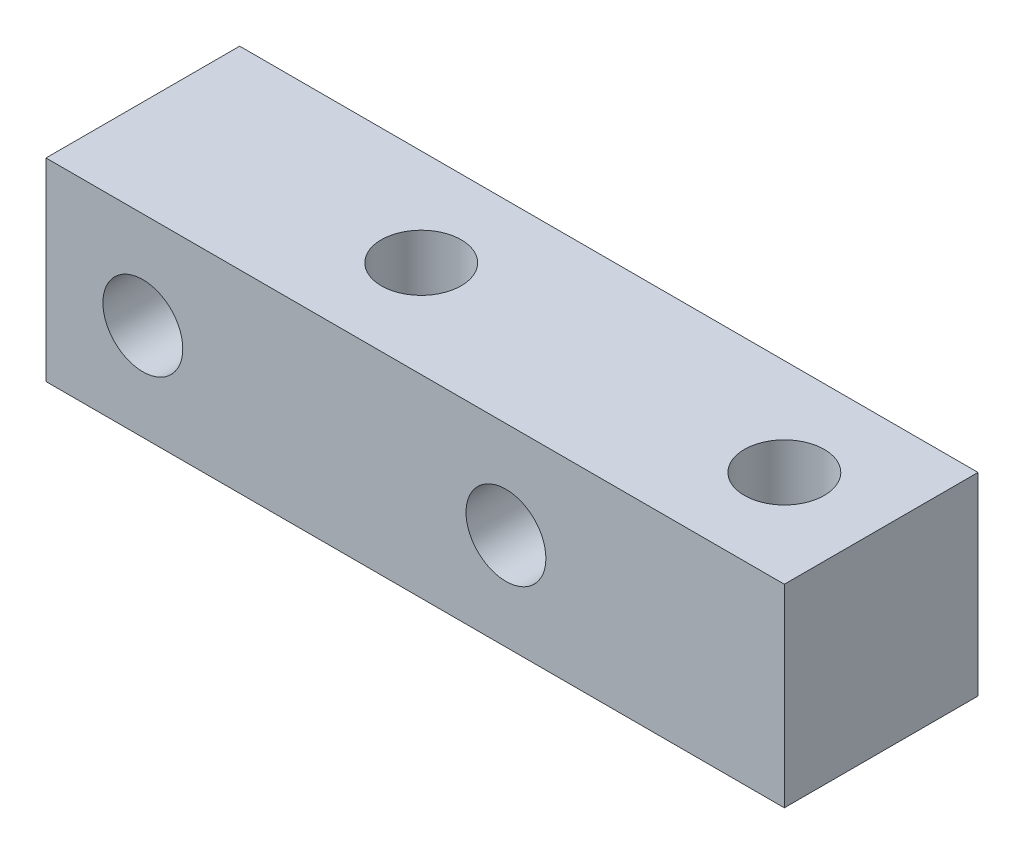
from build123d import *

# Parameters (mm, degrees)
SKETCH_1_W         = 30.5
SKETCH_1_H         = 8
EXTRUDE_1_DEPTH    = 8
HOLE_WIZARD_M4_1_D = 3.3
HOLE_WIZARD_M4_2_D = 3.3


with BuildPart() as part:
    # 草图1 → 凸台-拉伸1 (new body)
    with BuildSketch(Plane.XY):
        Rectangle(SKETCH_1_W, SKETCH_1_H)
    extrude(amount=EXTRUDE_1_DEPTH)

    # M4 螺纹孔1 (through all)
    with Locations(Plane(origin=(3.75, 0, 8), x_dir=(1, 0, 0), z_dir=(0, 0, 1))):
        with Locations((0, 0), (-15, 0)):
            Hole(HOLE_WIZARD_M4_1_D / 2)

    # M4 螺纹孔2 (through all)
    with Locations(Plane(origin=(-3.75, 4, 4), x_dir=(0, 0, 1), z_dir=(0, 1, 0))):
        with Locations((0, 0), (0, 15)):
            Hole(HOLE_WIZARD_M4_2_D / 2)


solid = part.part
